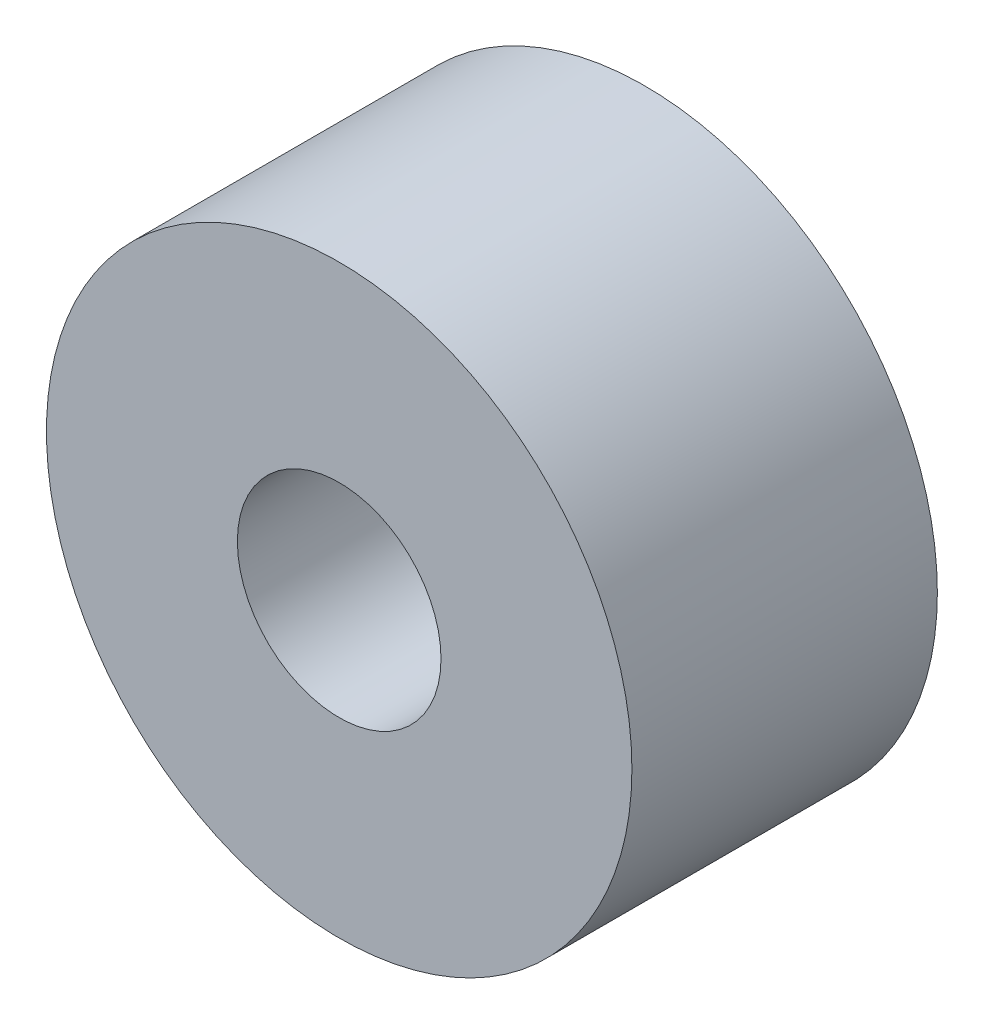
from build123d import *

# Parameters (mm, degrees)
SKETCH1_R           = 5.75
SKETCH1_R_2         = 2
BOSS_EXTRUDE1_DEPTH = 6


with BuildPart() as part:
    # Sketch1 → Boss-Extrude1 (new body)
    with BuildSketch(Plane.XY.offset(25.76684231)):
        Circle(SKETCH1_R)
        Circle(SKETCH1_R_2, mode=Mode.SUBTRACT)
    extrude(amount=BOSS_EXTRUDE1_DEPTH)


solid = part.part
